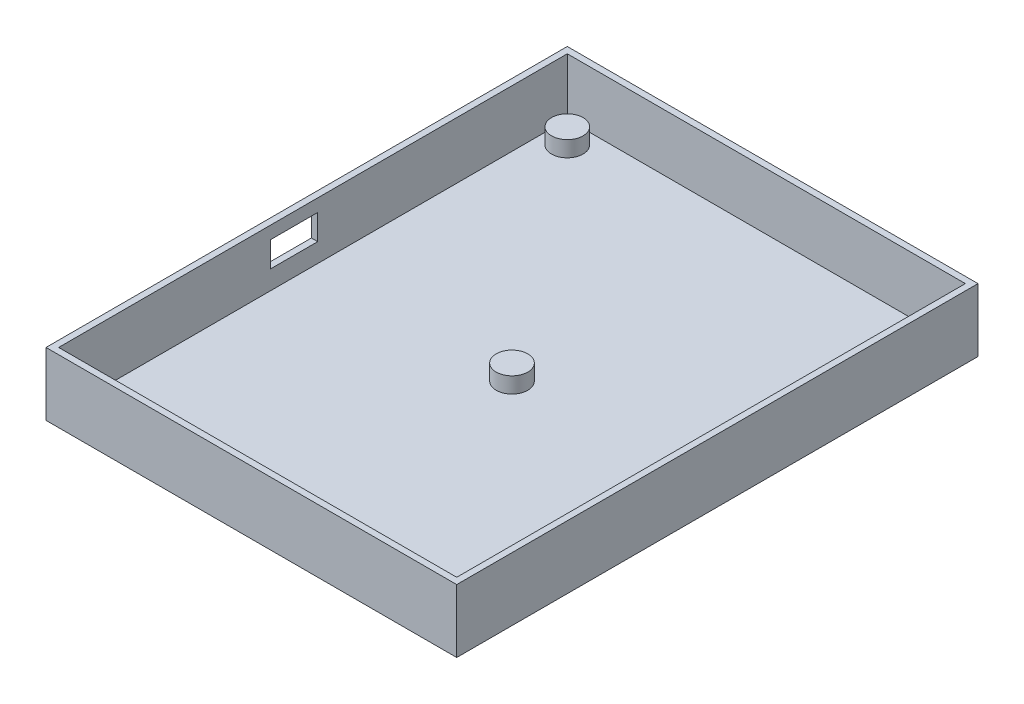
from build123d import *

# Parameters (mm, degrees)
SKETCH1_W           = 65
SKETCH1_H           = 82.5
BOSS_EXTRUDE1_DEPTH = 10
SKETCH2_W           = 63
SKETCH2_H           = 80.5
CUT_EXTRUDE1_DEPTH  = 9
SKETCH4_R           = 2.5
BOSS_EXTRUDE2_DEPTH = 2.5
SKETCH5_W           = 7.5
SKETCH5_H           = 4
CUT_EXTRUDE2_DEPTH  = 1


with BuildPart() as part:
    # Sketch1 → Boss-Extrude1 (new body)
    with BuildSketch(Plane(origin=(0, 0, 0), x_dir=(1, 0, 0), z_dir=(0, 1, 0))):
        Rectangle(SKETCH1_W, SKETCH1_H)
    extrude(amount=BOSS_EXTRUDE1_DEPTH)

    # Sketch2 → Cut-Extrude1 (cut)
    with BuildSketch(Plane(origin=(0, 10, 0), x_dir=(1, 0, 0), z_dir=(0, 1, 0))):
        Rectangle(SKETCH2_W, SKETCH2_H)
    extrude(amount=-CUT_EXTRUDE1_DEPTH, mode=Mode.SUBTRACT)

    # Sketch4 → Boss-Extrude2 (add)
    with BuildSketch(Plane(origin=(0, 1, 0), x_dir=(1, 0, 0), z_dir=(0, 1, 0))):
        with Locations((-28, 36.75)):
            Circle(SKETCH4_R)
        with Locations((28, 36.75)):
            Circle(SKETCH4_R)
        with Locations((-28, -36.75)):
            Circle(SKETCH4_R)
        with Locations((28, -36.75)):
            Circle(SKETCH4_R)
        Circle(SKETCH4_R)
    extrude(amount=BOSS_EXTRUDE2_DEPTH)

    # Sketch5 → Cut-Extrude2 (cut)
    with BuildSketch(Plane.ZY.offset(32.5)):
        with Locations((3, 6)):
            Rectangle(SKETCH5_W, SKETCH5_H)
    extrude(amount=-CUT_EXTRUDE2_DEPTH, mode=Mode.SUBTRACT)


solid = part.part
